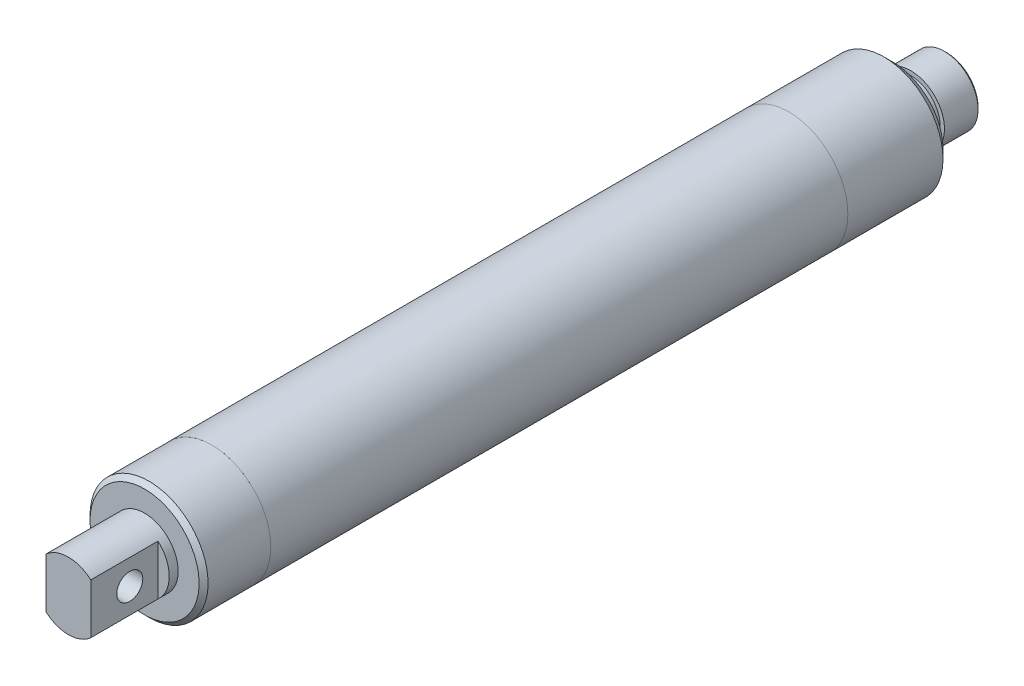
from build123d import *

# Parameters (mm, degrees)
SKETCH1_R               = 16.73225
SKETCH1_R_2             = 15.403927615
CYCLENDAR_DEPTH         = 163.576
SKETCH2_R               = 16.73225
SKETCH2_R_2             = 5.588
NOSE_DEPTH              = 29.5148
NOSE_CHAMFER_SIZE       = 2.54
CUT_EXTRUDE1_REACH      = 167.279
CUT_EXTRUDE1_END_RADIUS = 16.73225
SKETCH3_R               = 5.08
SKETCH6_R               = 16.73225
TAIL_DEPTH              = 19.05
TAIL_CHAMFER_SIZE       = 1.27
SKETCH7_R               = 9.525
TAIL_MOUNT_DEPTH        = 2.54
SKETCH8_R               = 9.525
BOSS_EXTRUDE5_DEPTH     = 19.05
CUT_EXTRUDE2_REACH      = 207.582
CUT_EXTRUDE2_END_RADIUS = 16.73225
SKETCH9_R               = 5.08
SKETCH10_W              = 8.464736822
SKETCH10_H              = 19.05
SKETCH10_W_2            = 6.449526643
CUT_EXTRUDE3_DEPTH      = 19.05
SKETCH11_R              = 3.683
CUT_EXTRUDE4_DEPTH      = 12.7
SKETCH12_R              = 7.62
CUT_EXTRUDE5_DEPTH      = 13.97


with BuildPart() as part:
    # Sketch1 → Cyclendar (new body)
    with BuildSketch(Plane.XY):
        Circle(SKETCH1_R)
        Circle(SKETCH1_R_2, mode=Mode.SUBTRACT)
    extrude(amount=CYCLENDAR_DEPTH)


with BuildPart() as body_2:
    # Sketch2 → Nose (new body)
    with BuildSketch(Plane.XY):
        Circle(SKETCH2_R)
        Circle(SKETCH2_R_2, mode=Mode.SUBTRACT)
    extrude(amount=-NOSE_DEPTH)

    # Nose_Chamfer
    nose_chamfer_edges = [body_2.edges().sort_by_distance(p)[0] for p in [
        (-16.73225, 0, -29.5148),
    ]]
    chamfer(nose_chamfer_edges, length=NOSE_CHAMFER_SIZE)

    # Cut-Extrude1: up to this cylinder (the profile starts inside it)
    cut_extrude1_end = Plane(origin=(0, 0, -11.049), z_dir=(0, 0, 1)) * Cylinder(CUT_EXTRUDE1_END_RADIUS, 369.0225, mode=Mode.PRIVATE)
    # Sketch3 → Cut-Extrude1 (cut, up to the surface)
    with BuildSketch(Plane(origin=(0, 0, 0), x_dir=(0, 0, -1), z_dir=(1, 0, 0)), mode=Mode.PRIVATE) as cut_extrude1_sk1:
        with Locations((11.049, 0)):
            Circle(SKETCH3_R)
    cut_extrude1_tool1 = extrude(cut_extrude1_sk1.sketch, amount=-CUT_EXTRUDE1_REACH, mode=Mode.PRIVATE) & cut_extrude1_end
    add(cut_extrude1_tool1.solids().sort_by_distance((0, 0, -11.049))[0], mode=Mode.SUBTRACT)

    # Sketch4 → Revolve1 (revolve)
    with BuildSketch(Plane(origin=(0, 0, 0), x_dir=(1, 0, 0), z_dir=(0, 1, 0))):
        Polygon((-8.89, 44.7548), (-9.525, 44.1198), (-9.525, 34.5948), (-8.3185, 34.5948), (-8.3185, 31.4198), (-9.525, 31.4198), (-9.525, 29.5148), (-5.588, 29.5148), (-5.588, 44.7548), align=None)
    revolve(axis=Axis((0, 0, -26.9748), (0, 0, 1)))


with BuildPart() as body_3:
    # Sketch6 → Tail (new body)
    with BuildSketch(Plane.XY.offset(163.576)):
        with Locations(Location((0, 0, 0), (0, 0, 180))):
            Circle(SKETCH6_R)
    extrude(amount=TAIL_DEPTH)

    # Tail_Chamfer
    tail_chamfer_edges = [body_3.edges().sort_by_distance(p)[0] for p in [
        (16.73225, 0, 182.626),
    ]]
    chamfer(tail_chamfer_edges, length=TAIL_CHAMFER_SIZE)

    # Sketch7 → Tail_Mount (add)
    with BuildSketch(Plane.XY.offset(182.626)):
        Circle(SKETCH7_R)
    extrude(amount=TAIL_MOUNT_DEPTH)

    # Sketch8 → Boss-Extrude5 (add)
    with BuildSketch(Plane.XY.offset(185.166)):
        Circle(SKETCH8_R)
    extrude(amount=BOSS_EXTRUDE5_DEPTH)

    # Cut-Extrude2: up to this cylinder (the profile starts inside it)
    cut_extrude2_end = Plane(origin=(0, 0, 174.752), z_dir=(0, 0, -1)) * Cylinder(CUT_EXTRUDE2_END_RADIUS, 449.6285, mode=Mode.PRIVATE)
    # Sketch9 → Cut-Extrude2 (cut, up to the surface)
    with BuildSketch(Plane(origin=(0, 0, 0), x_dir=(0, 0, -1), z_dir=(1, 0, 0)), mode=Mode.PRIVATE) as cut_extrude2_sk1:
        with Locations((-174.752, 0)):
            Circle(SKETCH9_R)
    cut_extrude2_tool1 = extrude(cut_extrude2_sk1.sketch, amount=-CUT_EXTRUDE2_REACH, mode=Mode.PRIVATE) & cut_extrude2_end
    add(cut_extrude2_tool1.solids().sort_by_distance((0, 0, 174.752))[0], mode=Mode.SUBTRACT)

    # Sketch10 → Cut-Extrude3 (cut)
    with BuildSketch(Plane.XY.offset(204.216)):
        with Locations((10.582368411, 0)):
            Rectangle(SKETCH10_W, SKETCH10_H)
        with Locations((-9.574763322, 0)):
            Rectangle(SKETCH10_W_2, SKETCH10_H)
    extrude(amount=-CUT_EXTRUDE3_DEPTH, mode=Mode.SUBTRACT)

    # Sketch11 → Cut-Extrude4 (cut)
    with BuildSketch(Plane.ZY.offset(6.35)):
        with Locations(Location((193.167, 0, 0), (0, 0, 270))):
            Circle(SKETCH11_R)
    extrude(amount=-CUT_EXTRUDE4_DEPTH, mode=Mode.SUBTRACT)

    # Sketch12 → Cut-Extrude5 (cut)
    with BuildSketch(Plane(origin=(0, 0, 163.576), x_dir=(-1, 0, 0), z_dir=(0, 0, -1))):
        Circle(SKETCH12_R)
    extrude(amount=-CUT_EXTRUDE5_DEPTH, mode=Mode.SUBTRACT)


solid = Compound([part.part, body_2.part, body_3.part])
